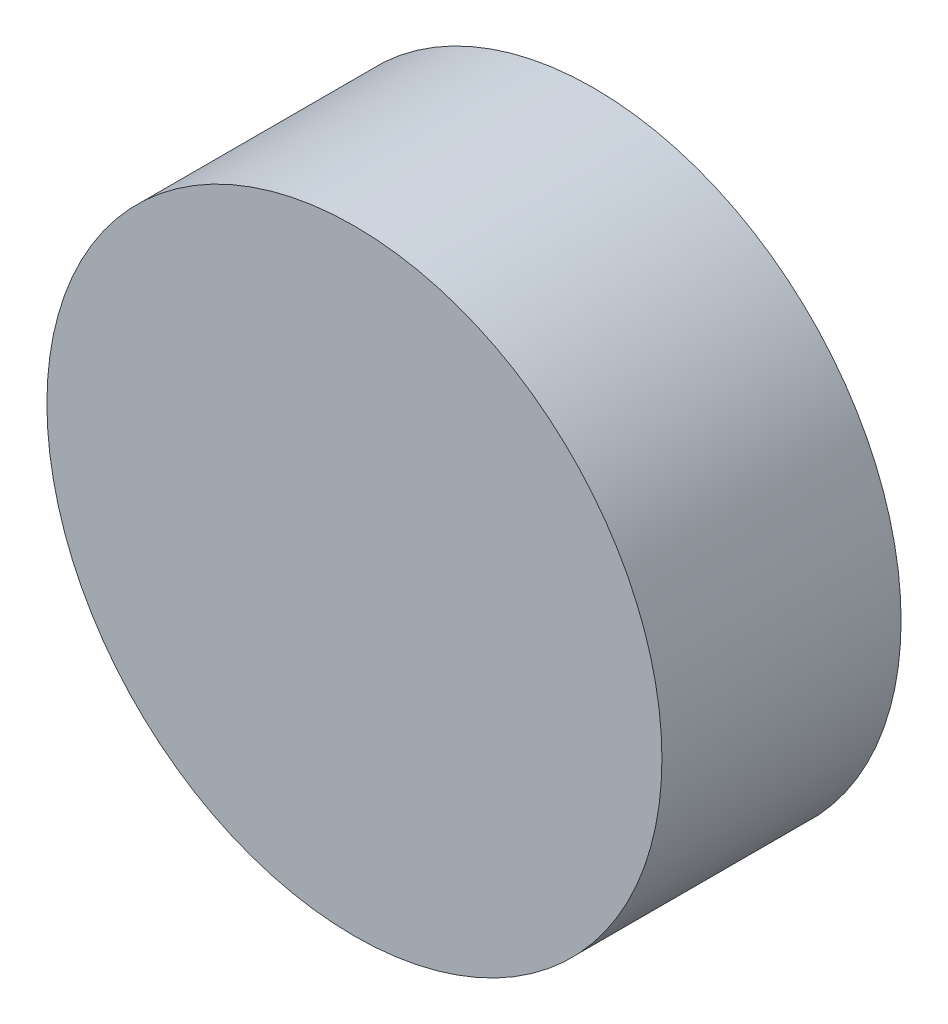
from build123d import *

# Parameters (mm, degrees)
SKETCH1_R           = 9
BOSS_EXTRUDE3_DEPTH = 7


with BuildPart() as part:
    # Sketch1 → Boss-Extrude3 (new body)
    with BuildSketch(Plane.XY):
        with Locations((-14.146484292, 25.061606325)):
            Circle(SKETCH1_R)
    extrude(amount=BOSS_EXTRUDE3_DEPTH)


solid = part.part
